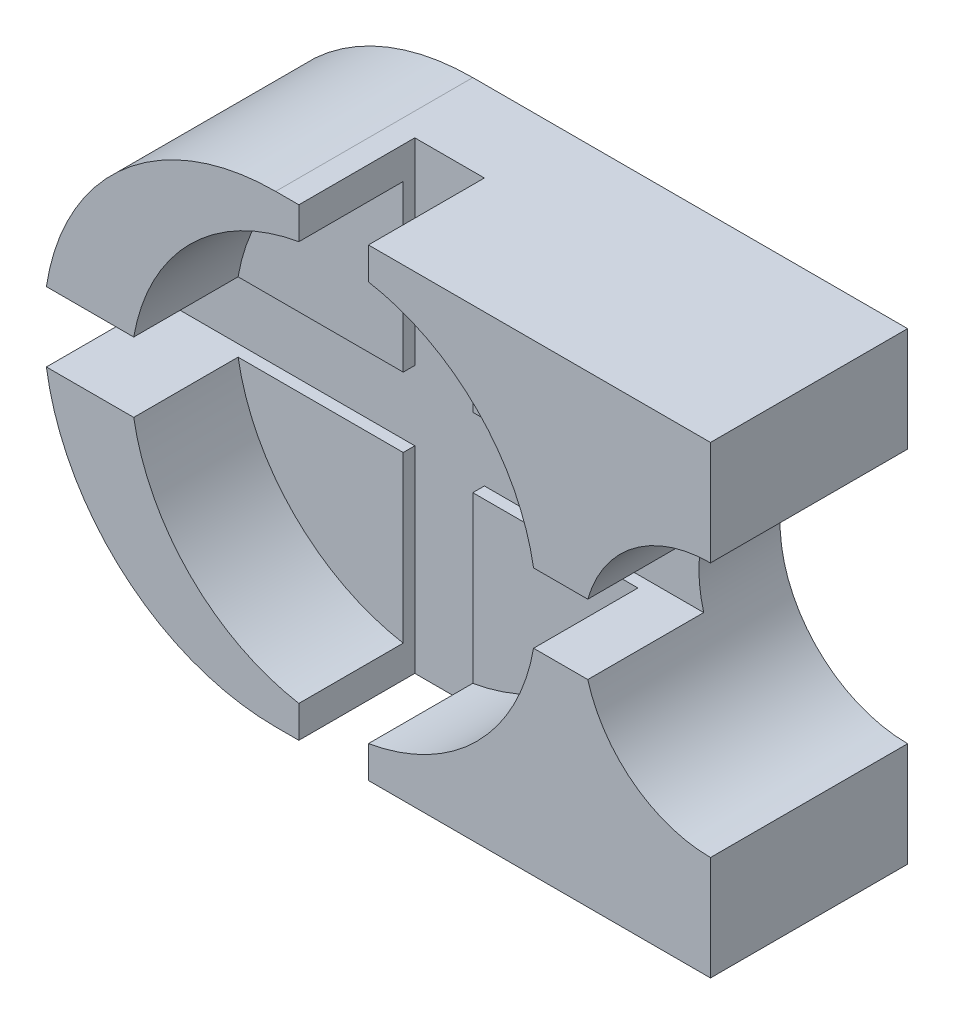
from build123d import *

# Parameters (mm, degrees)
BOSS_EXTRUDE1_DEPTH = 34
SKETCH3_R           = 35
CUT_EXTRUDE1_DEPTH  = 18
CUT_EXTRUDE2_DEPTH  = 20


with BuildPart() as part:
    # Sketch1 → Boss-Extrude1 (new body)
    with BuildSketch(Plane.XY):
        with BuildLine():
            Line((75, 40), (0, 40))
            ThreePointArc((0, 40), (-40, 0), (0, -40))
            Line((0, -40), (75, -40))
            Line((75, -40), (75, -22))
            ThreePointArc((75, -22), (53, 0), (75, 22))
            Line((75, 22), (75, 40))
        make_face()
    extrude(amount=BOSS_EXTRUDE1_DEPTH)

    # Sketch3 → Cut-Extrude1 (cut)
    with BuildSketch(Plane.XY.offset(34)):
        with Locations((10, 0)):
            Circle(SKETCH3_R)
    extrude(amount=-CUT_EXTRUDE1_DEPTH, mode=Mode.SUBTRACT)

    # Sketch4 → Cut-Extrude2 (cut)
    with BuildSketch(Plane.XY.offset(34)):
        with BuildLine():
            ThreePointArc((53.833989511, -6), (53, 0), (53.833989511, 6))
            Line((53.833989511, 6), (44.481879299, 6))
            Line((44.481879299, 6), (16, 6))
            Line((16, 6), (16, 34.481879299))
            Line((16, 34.481879299), (16, 40))
            Line((16, 40), (4, 40))
            Line((4, 40), (4, 34.481879299))
            Line((4, 34.481879299), (4, 6))
            Line((4, 6), (-24.481879299, 6))
            Line((-24.481879299, 6), (-39.547439867, 6))
            ThreePointArc((-39.547439867, 6), (-40, 0), (-39.547439867, -6))
            Line((-39.547439867, -6), (-24.481879299, -6))
            Line((-24.481879299, -6), (4, -6))
            Line((4, -6), (4, -34.481879299))
            Line((4, -34.481879299), (4, -40))
            Line((4, -40), (16, -40))
            Line((16, -40), (16, -34.481879299))
            Line((16, -34.481879299), (16, -6))
            Line((16, -6), (44.481879299, -6))
            Line((44.481879299, -6), (53.833989511, -6))
        make_face()
    extrude(amount=-CUT_EXTRUDE2_DEPTH, mode=Mode.SUBTRACT)


solid = part.part
